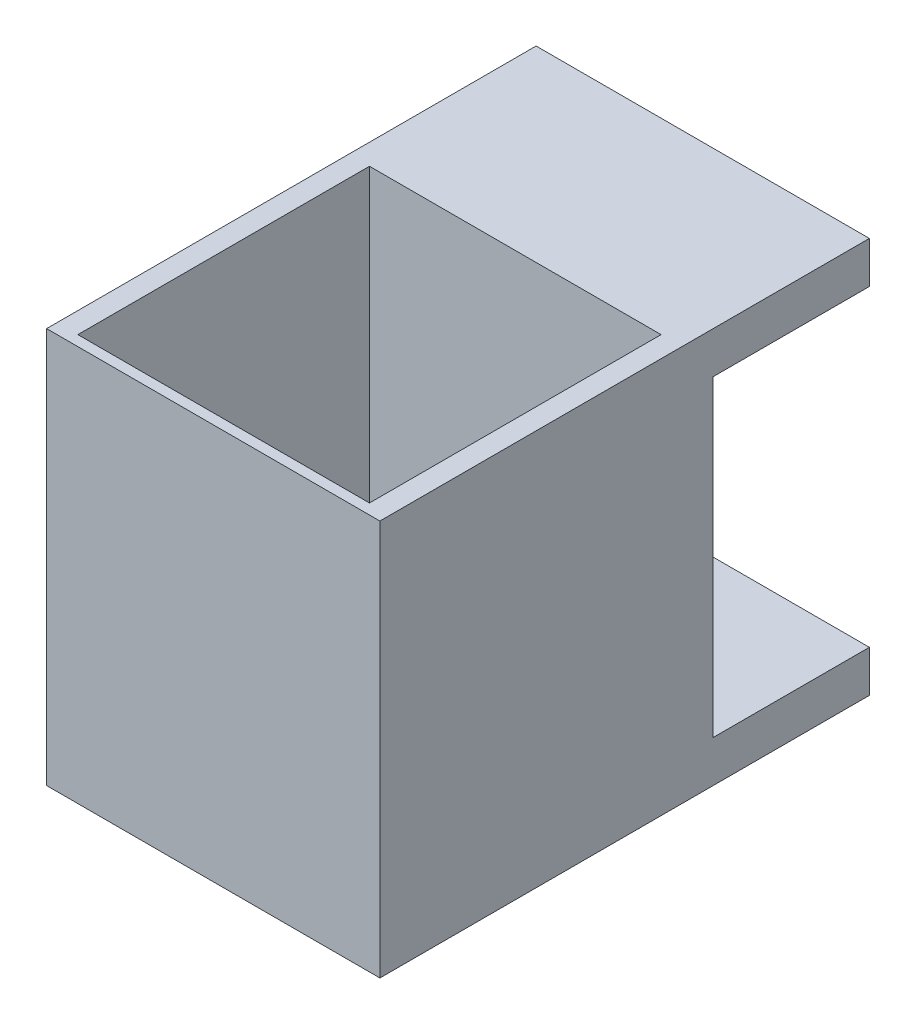
from build123d import *

# Parameters (mm, degrees)
BOSS_EXTRUDE1_DEPTH = 16
SKETCH2_W           = 28
SKETCH2_H           = 28
CUT_EXTRUDE1_DEPTH  = 39
SKETCH3_R           = 1
CUT_EXTRUDE2_DEPTH  = 2


with BuildPart() as part:
    # Sketch1 → Boss-Extrude1 (new body, symmetric)
    with BuildSketch(Plane(origin=(0, 0, 0), x_dir=(0, 0, -1), z_dir=(1, 0, 0))):
        Polygon((0, 0), (0, 38), (47, 38), (47, 34), (32, 34), (32, 4), (47, 4), (47, 0), align=None)
    extrude(amount=BOSS_EXTRUDE1_DEPTH, both=True)

    # Sketch2 → Cut-Extrude1 (cut, through all)
    with BuildSketch(Plane(origin=(0, 38, 0), x_dir=(1, 0, 0), z_dir=(0, 1, 0))):
        with Locations((0, 15)):
            Rectangle(SKETCH2_W, SKETCH2_H)
    extrude(amount=-CUT_EXTRUDE1_DEPTH, mode=Mode.SUBTRACT)

    # Sketch3 → Cut-Extrude2 (cut)
    with BuildSketch(Plane(origin=(0, 0, -47), x_dir=(-1, 0, 0), z_dir=(0, 0, -1))):
        with Locations((0, 36)):
            Circle(SKETCH3_R)
        with Locations((0, 2)):
            Circle(SKETCH3_R)
    extrude(amount=-CUT_EXTRUDE2_DEPTH, mode=Mode.SUBTRACT)


solid = part.part
